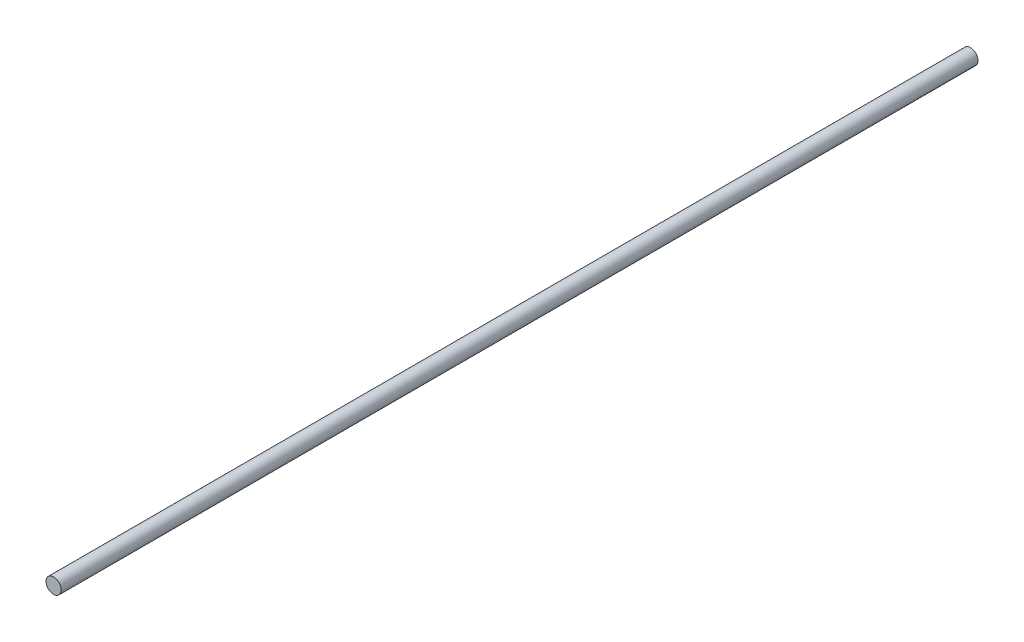
from build123d import *

# Parameters (mm, degrees)
SKETCH1_R           = 0.1
BOSS_EXTRUDE1_DEPTH = 12.1


with BuildPart() as part:
    # Sketch1 → Boss-Extrude1 (new body)
    with BuildSketch(Plane.XY):
        Circle(SKETCH1_R)
    extrude(amount=BOSS_EXTRUDE1_DEPTH)


solid = part.part
